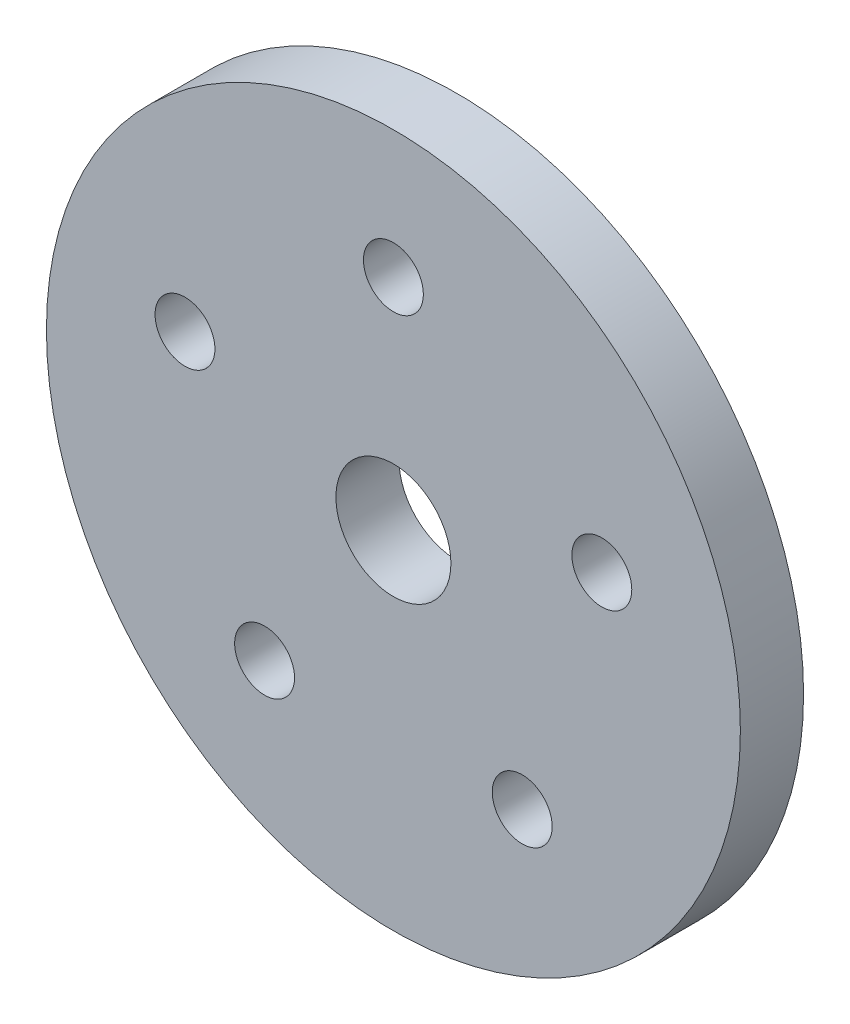
from build123d import *

# Parameters (mm, degrees)
SKETCH1_R           = 24.13
SKETCH1_R_2         = 2.0828
SKETCH1_R_3         = 4
BOSS_EXTRUDE1_DEPTH = 4.3942


with BuildPart() as part:
    # Sketch1 → Boss-Extrude1 (new body)
    with BuildSketch(Plane.XY):
        Circle(SKETCH1_R)
        with Locations((0, 15.24)):
            Circle(SKETCH1_R_2, mode=Mode.SUBTRACT)
        with Locations((14.494101308, 4.709418994)):
            Circle(SKETCH1_R_2, mode=Mode.SUBTRACT)
        with Locations((8.957847245, -12.329418994)):
            Circle(SKETCH1_R_2, mode=Mode.SUBTRACT)
        with Locations((-8.957847245, -12.329418994)):
            Circle(SKETCH1_R_2, mode=Mode.SUBTRACT)
        with Locations((-14.494101308, 4.709418994)):
            Circle(SKETCH1_R_2, mode=Mode.SUBTRACT)
        Circle(SKETCH1_R_3, mode=Mode.SUBTRACT)
    extrude(amount=BOSS_EXTRUDE1_DEPTH)


solid = part.part
